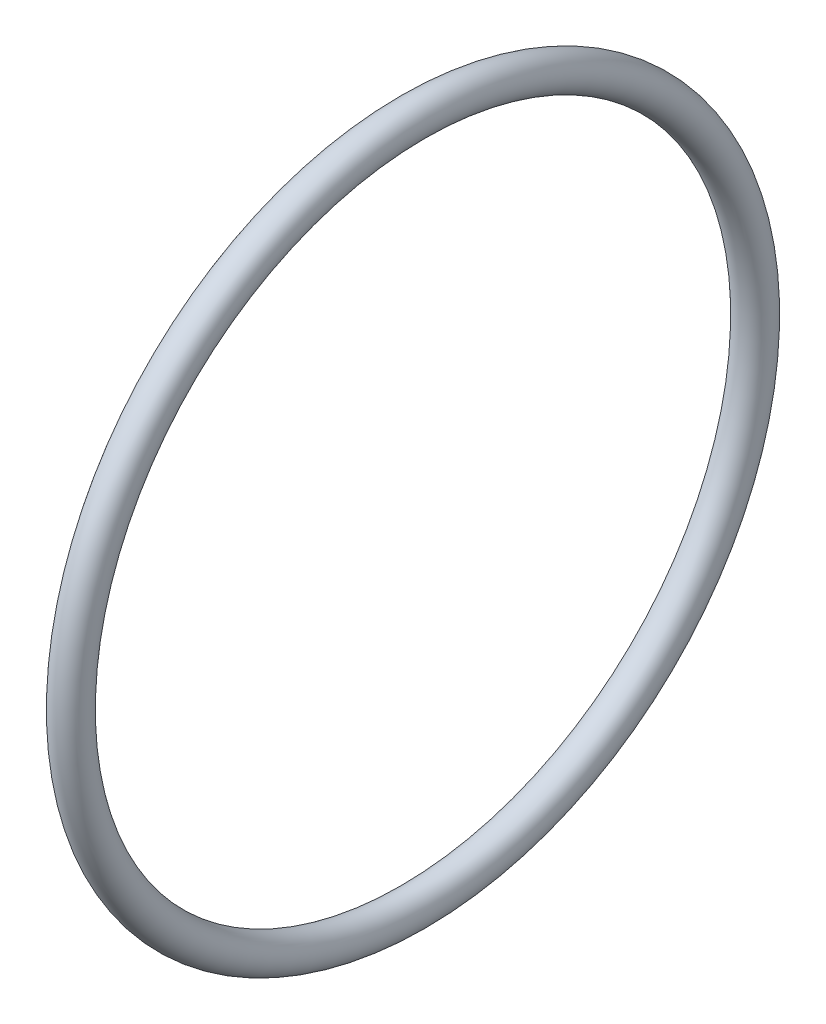
from build123d import *

# Parameters (mm, degrees)
SKETCH1_R = 0.635


with BuildPart() as part:
    # Sketch1 → Revolve1 (revolve)
    with BuildSketch(Plane.XY):
        with Locations((-16.51, 1445.334910137)):
            Circle(SKETCH1_R)
    revolve(axis=Axis((-22.86, 1432.787310137, 0), (1, 0, 0)))


solid = part.part
